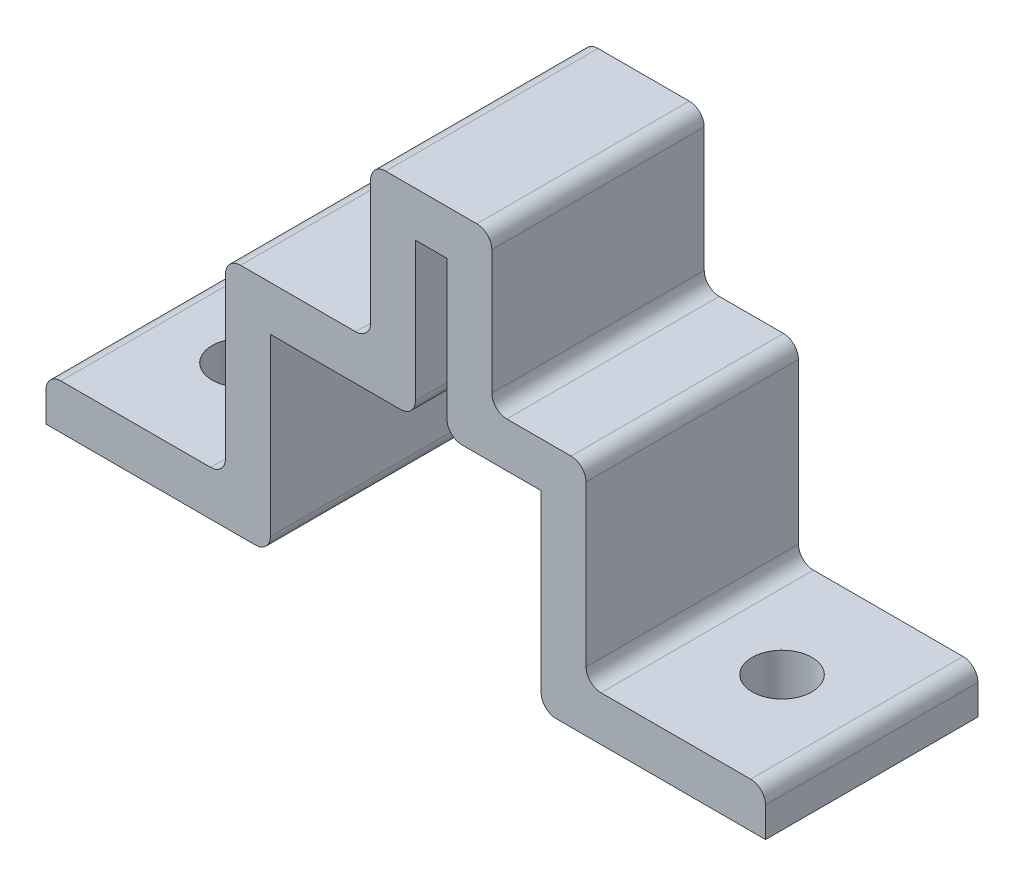
from build123d import *

# Parameters (mm, degrees)
BOSS_EXTRUDE1_DEPTH = 14.2
SKETCH2_R           = 2
CUT_EXTRUDE1_DEPTH  = 3


with BuildPart() as part:
    # Sketch1 → Boss-Extrude1 (new body)
    with BuildSketch(Plane.XY):
        with BuildLine():
            Line((0, 0), (12, 0))
            Line((12, 0), (14, 0))
            ThreePointArc((14, 0), (14.707106781, 0.292893219), (15, 1))
            Line((15, 1), (15, 12.7))
            Line((15, 12.7), (23.7, 12.7))
            ThreePointArc((23.7, 12.7), (24.407106781, 12.992893219), (24.7, 13.7))
            Line((24.7, 13.7), (24.7, 23))
            Line((24.7, 23), (26.8, 23))
            Line((26.8, 23), (26.8, 13.7))
            ThreePointArc((26.8, 13.7), (27.092893219, 12.992893219), (27.8, 12.7))
            Line((27.8, 12.7), (33.1, 12.7))
            Line((33.1, 12.7), (33.1, 1))
            ThreePointArc((33.1, 1), (33.392893219, 0.292893219), (34.1, 0))
            Line((34.1, 0), (48.1, 0))
            Line((48.1, 0), (48.1, 2))
            ThreePointArc((48.1, 2), (47.807106781, 2.707106781), (47.1, 3))
            Line((47.1, 3), (37.1, 3))
            ThreePointArc((37.1, 3), (36.392893219, 3.292893219), (36.1, 4))
            Line((36.1, 4), (36.1, 14.7))
            ThreePointArc((36.1, 14.7), (35.807106781, 15.407106781), (35.1, 15.7))
            Line((35.1, 15.7), (30.8, 15.7))
            ThreePointArc((30.8, 15.7), (30.092893219, 15.992893219), (29.8, 16.7))
            Line((29.8, 16.7), (29.8, 25))
            ThreePointArc((29.8, 25), (29.507106781, 25.707106781), (28.8, 26))
            Line((28.8, 26), (22.7, 26))
            ThreePointArc((22.7, 26), (21.992893219, 25.707106781), (21.7, 25))
            Line((21.7, 25), (21.7, 16.7))
            ThreePointArc((21.7, 16.7), (21.407106781, 15.992893219), (20.7, 15.7))
            Line((20.7, 15.7), (13, 15.7))
            ThreePointArc((13, 15.7), (12.292893219, 15.407106781), (12, 14.7))
            Line((12, 14.7), (12, 4))
            ThreePointArc((12, 4), (11.707106781, 3.292893219), (11, 3))
            Line((11, 3), (1, 3))
            ThreePointArc((1, 3), (0.292893219, 2.707106781), (0, 2))
            Line((0, 2), (0, 0))
        make_face()
    extrude(amount=-BOSS_EXTRUDE1_DEPTH)

    # Sketch2 → Cut-Extrude1 (cut)
    with BuildSketch(Plane(origin=(0, 0, 0), x_dir=(1, 0, 0), z_dir=(0, 1, 0))):
        with Locations(Location((42.1, 7.1, 0), (0, 0, 180))):  # turned: the seam where the file's is
            Circle(SKETCH2_R)
        with Locations(Location((6, 7.1, 0), (0, 0, 180))):  # turned: the seam where the file's is
            Circle(SKETCH2_R)
    extrude(amount=CUT_EXTRUDE1_DEPTH, mode=Mode.SUBTRACT)


solid = part.part
